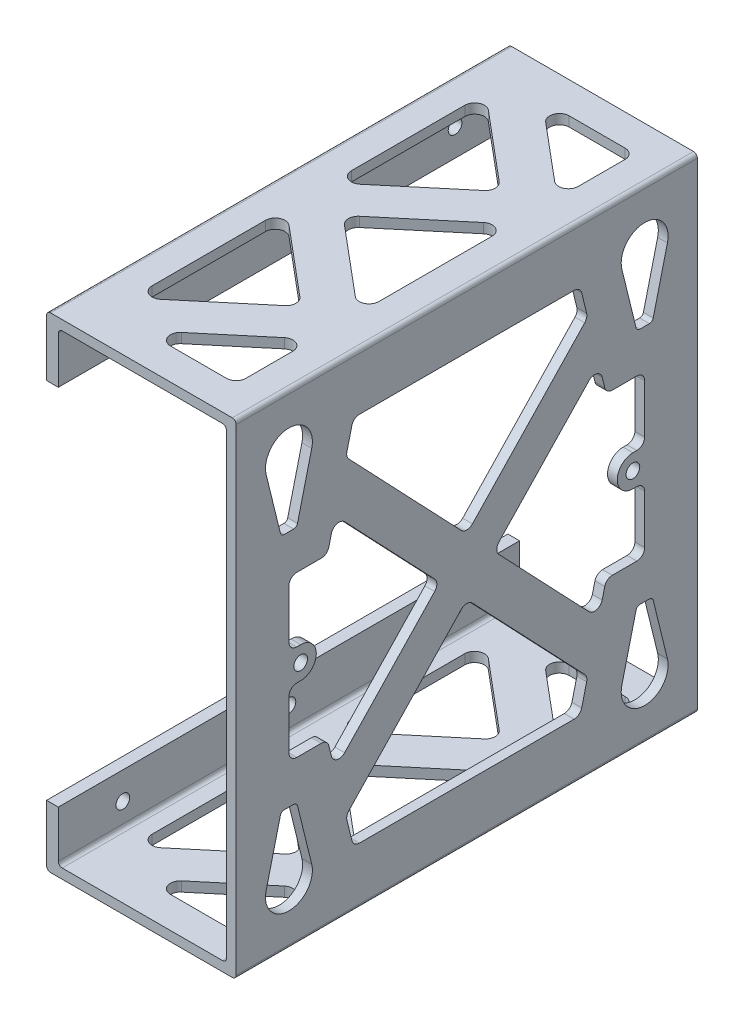
from build123d import *

# Parameters (mm, degrees)
EXTRUDE_1_DEPTH                          = 118
CUT_EXTRUDE_1_DEPTH                      = 2.5
SKETCH_3_R                               = 1.75
CUT_EXTRUDE_2_DEPTH                      = 3
MIRROR2_AT_THE_SECOND_PLANE_COPY_1_DEPTH = 2.5
FILLET1_R                                = 1
CUT_EXTRUDE_3_DEPTH                      = 2.5
MIRROR3_AT_THE_SECOND_PLANE_COPY_1_DEPTH = 2.5
FILLET2_R                                = 2
SKETCH1_R                                = 1.75
BOSS_EXTRUDE1_DEPTH                      = 2.5
FILLET3_R                                = 2
CUT_EXTRUDE_4_DEPTH                      = 124
FILLET_3_R                               = 2.5
FILLET_2_R                               = 1


with BuildPart() as part:
    # Sketch 1 → Extrude 1 (new body)
    with BuildSketch(Plane.XY):
        Polygon((0, 15.5), (0, 0), (48.5, 0), (48.5, 124), (0, 124), (0, 108.5), (3, 108.5), (3, 121.5), (46, 121.5), (46, 2.5), (3, 2.5), (3, 15.5), align=None)
    extrude(amount=-EXTRUDE_1_DEPTH)

    # Sketch 2 → Cut-Extrude 1 (cut)
    with BuildSketch(Plane.ZY.offset(-46)):
        with BuildLine():
            Line((-15.5, 92.5), (-11.5, 92.5))
            Line((-11.5, 92.5), (-7.673432105, 108.067831517))
            ThreePointArc((-7.673432105, 108.067831517), (-13.5, 115.5), (-19.326567895, 108.067831517))
            Line((-19.326567895, 108.067831517), (-15.5, 92.5))
        make_face()
    cut_extrude_1 = extrude(amount=-CUT_EXTRUDE_1_DEPTH, mode=Mode.SUBTRACT)

    # Sketch 3 → Cut-Extrude 2 (cut)
    with BuildSketch(Plane.ZY):
        with Locations((-101.5, 115.5)):
            Circle(SKETCH_3_R)
        with Locations((-59, 115.5)):
            Circle(SKETCH_3_R)
        with Locations((-16.5, 115.5)):
            Circle(SKETCH_3_R)
        with Locations((-16.5, 8.5)):
            Circle(SKETCH_3_R)
        with Locations((-59, 8.5)):
            Circle(SKETCH_3_R)
        with Locations((-101.5, 8.5)):
            Circle(SKETCH_3_R)
    extrude(amount=-CUT_EXTRUDE_2_DEPTH, mode=Mode.SUBTRACT)

    # Mirror2: Cut-Extrude 1 across plane
    add(cut_extrude_1.mirror(Plane.ZX.offset(62)), mode=Mode.SUBTRACT)

    # Mirror2 at the second plane: Cut-Extrude 1 across plane
    add(cut_extrude_1.mirror(Plane.XY.offset(-59)), mode=Mode.SUBTRACT)

    # Mirror2 at the second plane copy 1 sketc → Mirror2 at the second plane copy 1 (cut)
    with BuildSketch(Plane(origin=(46, 124, -118), x_dir=(0, 0, -1), z_dir=(-1, 0, 0))):
        with BuildLine():
            Line((-15.5, 92.5), (-11.5, 92.5))
            Line((-11.5, 92.5), (-7.673432105, 108.067831517))
            ThreePointArc((-7.673432105, 108.067831517), (-13.5, 115.5), (-19.326567895, 108.067831517))
            Line((-19.326567895, 108.067831517), (-15.5, 92.5))
        make_face()
    extrude(amount=-MIRROR2_AT_THE_SECOND_PLANE_COPY_1_DEPTH, mode=Mode.SUBTRACT)

    # Fillet1
    fillet1_edges = [part.edges().sort_by_distance(p)[0] for p in [
        (47.25, 31.5, -106.5),
        (47.25, 31.5, -102.5),
        (47.25, 92.5, -11.5),
        (47.25, 92.5, -15.5),
        (47.25, 92.5, -106.5),
        (47.25, 92.5, -102.5),
        (47.25, 31.5, -11.5),
        (47.25, 31.5, -15.5),
    ]]
    fillet(fillet1_edges, radius=FILLET1_R)

    # Sketch 4 → Cut-Extrude 3 (cut)
    with BuildSketch(Plane.ZY.offset(-46)):
        Polygon((-28.072165863, 101.753504842), (-59, 69.25306897), (-59, 109.5), (-29.976251839, 109.5), align=None)
        Polygon((-52.09788598, 62), (-13.5, 62), (-13.5, 82.5), (-23.33966067, 82.5), (-25.238493657, 90.225124137), align=None)
    cut_extrude_3 = extrude(amount=-CUT_EXTRUDE_3_DEPTH, mode=Mode.SUBTRACT)

    # Mirror3: Cut-Extrude 3 across plane
    add(cut_extrude_3.mirror(Plane.XY.offset(-59)), mode=Mode.SUBTRACT)

    # Mirror3 at the second plane: Cut-Extrude 3 across plane
    add(cut_extrude_3.mirror(Plane.ZX.offset(62)), mode=Mode.SUBTRACT)

    # Mirror3 at the second plane copy 1 sketc → Mirror3 at the second plane copy 1 (cut)
    with BuildSketch(Plane(origin=(46, 124, -118), x_dir=(0, 0, -1), z_dir=(-1, 0, 0))):
        Polygon((-28.072165863, 101.753504842), (-59, 69.25306897), (-59, 109.5), (-29.976251839, 109.5), align=None)
        Polygon((-52.09788598, 62), (-13.5, 62), (-13.5, 82.5), (-23.33966067, 82.5), (-25.238493657, 90.225124137), align=None)
    extrude(amount=-MIRROR3_AT_THE_SECOND_PLANE_COPY_1_DEPTH, mode=Mode.SUBTRACT)

    # Fillet2
    fillet2_edges = [part.edges().sort_by_distance(p)[0] for p in [
        (47.25, 109.5, -29.976251839),
        (47.25, 101.753504842, -28.072165863),
        (47.25, 69.25306897, -59),
        (47.25, 90.225124137, -25.238493657),
        (47.25, 82.5, -23.33966067),
        (47.25, 82.5, -13.5),
        (47.25, 62, -52.09788598),
        (47.25, 22.246495158, -28.072165863),
        (47.25, 14.5, -29.976251839),
        (47.25, 54.74693103, -59),
        (47.25, 41.5, -23.33966067),
        (47.25, 33.774875863, -25.238493657),
        (47.25, 41.5, -13.5),
        (47.25, 101.753504842, -89.927834137),
        (47.25, 109.5, -88.023748161),
        (47.25, 82.5, -94.66033933),
        (47.25, 90.225124137, -92.761506343),
        (47.25, 62, -65.90211402),
        (47.25, 82.5, -104.5),
        (47.25, 14.5, -88.023748161),
        (47.25, 22.246495158, -89.927834137),
        (47.25, 33.774875863, -92.761506343),
        (47.25, 41.5, -94.66033933),
        (47.25, 41.5, -104.5),
    ]]
    fillet(fillet2_edges, radius=FILLET2_R)

    # Sketch1 → Boss-Extrude1 (add)
    with BuildSketch(Plane(origin=(48.5, 0, 0), x_dir=(0, 0, -1), z_dir=(1, 0, 0))):
        with BuildLine():
            Line((101.5, 66), (104.5, 66))
            Line((104.5, 66), (104.5, 58))
            Line((104.5, 58), (101.5, 58))
            ThreePointArc((101.5, 58), (97.5, 62), (101.5, 66))
        make_face()
        with Locations((101.5, 62)):
            Circle(SKETCH1_R, mode=Mode.SUBTRACT)
        with BuildLine():
            Line((16.5, 66), (13.5, 66))
            Line((13.5, 66), (13.5, 58))
            Line((13.5, 58), (16.5, 58))
            ThreePointArc((16.5, 58), (20.5, 62), (16.5, 66))
        make_face()
        with Locations((16.5, 62)):
            Circle(SKETCH1_R, mode=Mode.SUBTRACT)
    extrude(amount=-BOSS_EXTRUDE1_DEPTH)

    # Fillet3
    fillet3_edges = [part.edges().sort_by_distance(p)[0] for p in [
        (47.25, 58, -13.5),
        (47.25, 66, -13.5),
        (47.25, 66, -104.5),
        (47.25, 58, -104.5),
    ]]
    fillet(fillet3_edges, radius=FILLET3_R)

    # Sketch 5 → Cut-Extrude 4 (cut)
    with BuildSketch(Plane.XZ):
        Polygon((40.5, -27.85833256), (40.5, -8), (16.833760829, -8), align=None)
        Polygon((8, -13.64166744), (31.666239171, -33.5), (8, -53.35833256), align=None)
        Polygon((40.5, -39.14166744), (16.833760829, -59), (40.5, -78.85833256), align=None)
        Polygon((31.666239171, -84.5), (8, -64.64166744), (8, -104.35833256), align=None)
        Polygon((40.5, -90.14166744), (40.5, -110), (16.833760829, -110), align=None)
    extrude(amount=-CUT_EXTRUDE_4_DEPTH, mode=Mode.SUBTRACT)

    # Fillet 3
    fillet_3_edges = [part.edges().sort_by_distance(p)[0] for p in [
        (8, 1.25, -53.35833256),
        (8, 1.25, -13.64166744),
        (31.666239171, 1.25, -33.5),
        (8, 122.75, -53.35833256),
        (8, 122.75, -13.64166744),
        (31.666239171, 122.75, -33.5),
        (16.833760829, 1.25, -8),
        (40.5, 1.25, -8),
        (40.5, 1.25, -27.85833256),
        (16.833760829, 122.75, -8),
        (40.5, 122.75, -8),
        (40.5, 122.75, -27.85833256),
        (31.666239171, 1.25, -84.5),
        (8, 1.25, -104.35833256),
        (8, 1.25, -64.64166744),
        (31.666239171, 122.75, -84.5),
        (8, 122.75, -104.35833256),
        (8, 122.75, -64.64166744),
        (40.5, 1.25, -39.14166744),
        (40.5, 1.25, -78.85833256),
        (16.833760829, 1.25, -59),
        (40.5, 122.75, -39.14166744),
        (40.5, 122.75, -78.85833256),
        (16.833760829, 122.75, -59),
        (40.5, 1.25, -110),
        (16.833760829, 1.25, -110),
        (40.5, 1.25, -90.14166744),
        (40.5, 122.75, -110),
        (16.833760829, 122.75, -110),
        (40.5, 122.75, -90.14166744),
    ]]
    fillet(fillet_3_edges, radius=FILLET_3_R)

    # Fillet 2
    fillet_2_edges = [part.edges().sort_by_distance(p)[0] for p in [
        (3, 2.5, -59),
        (46, 2.5, -59),
        (46, 121.5, -59),
        (3, 121.5, -59),
        (0, 124, -59),
        (48.5, 124, -59),
        (48.5, 0, -59),
        (0, 0, -59),
    ]]
    fillet(fillet_2_edges, radius=FILLET_2_R)


solid = part.part
